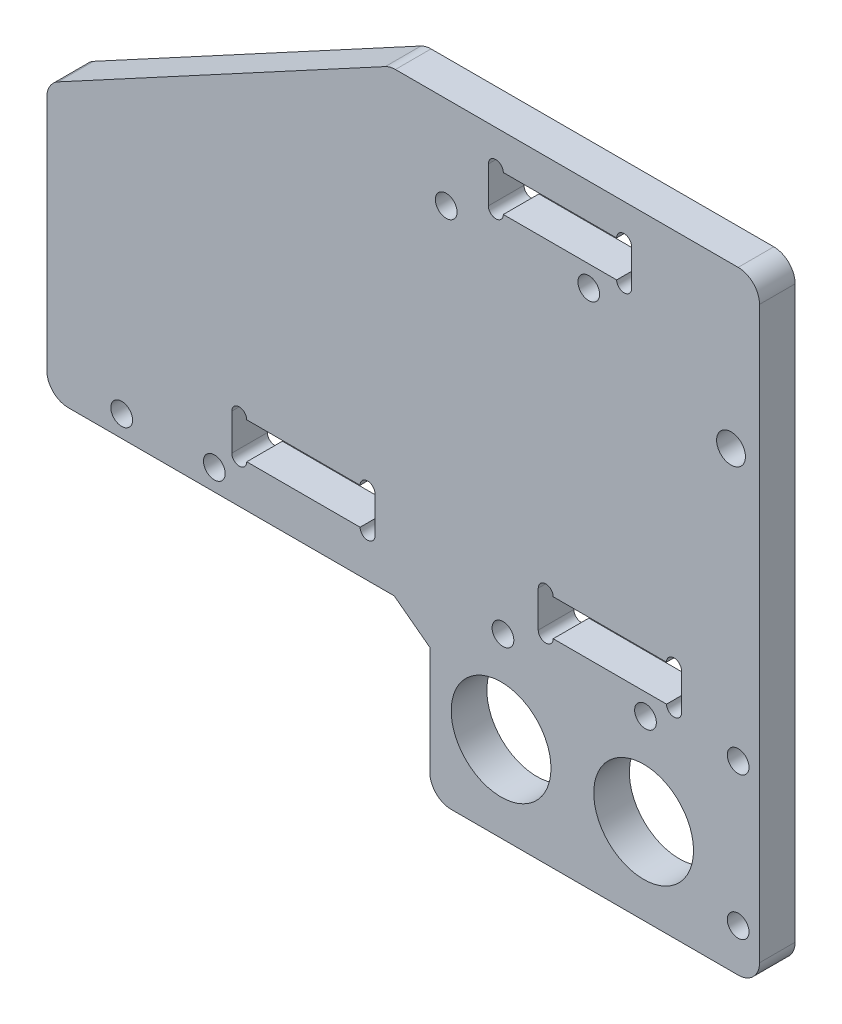
from build123d import *

# Parameters (mm, degrees)
EXTRUDE_1_DEPTH           = 5
SKETCH_4_W                = 20.1
SKETCH_4_H                = 5.1
CUT_EXTRUDE_3_DEPTH       = 1
CUT_EXTRUDE_3_DEPTH_BACK  = 6
CUT_EXTRUDE_4_DEPTH       = 6
SKETCH_6_R                = 1.525
CUT_EXTRUDE_5_DEPTH       = 1
CUT_EXTRUDE_5_DEPTH_BACK  = 6
CUT_EXTRUDE_6_DEPTH       = 1
CUT_EXTRUDE_6_DEPTH_BACK  = 6
SKETCH_8_W                = 53.737387097
SKETCH_8_H                = 38.025
EXTRUDE_2_DEPTH           = 5
SKETCH_11_R               = 1.525
CUT_EXTRUDE_9_DEPTH       = 1
CUT_EXTRUDE_9_DEPTH_BACK  = 6
SKETCH_14_R               = 2.025
CUT_EXTRUDE_10_DEPTH      = 10
SKETCH_15_W               = 2.1
SKETCH_15_H               = 5.1
SKETCH_15_W_2             = 15.9
CUT_EXTRUDE_11_DEPTH      = 6
SKETCH_16_R               = 1.525
CUT_EXTRUDE_12_DEPTH      = 1
CUT_EXTRUDE_12_DEPTH_BACK = 6
CUT_EXTRUDE_13_DEPTH      = 10
EXTRUDE_3_DEPTH           = 5
EXTRUDE_4_DEPTH           = 5
FILLET_1_R                = 3
SKETCH_20_R               = 7
CUT_EXTRUDE_14_DEPTH      = 5
SKETCH_21_R               = 1.525
CUT_EXTRUDE_15_DEPTH      = 8
CUT_EXTRUDE_17_DEPTH      = 6


with BuildPart() as part:
    # 草图1 → 凸台-拉伸1 (new body)
    with BuildSketch(Plane.XY):
        Polygon((0, 0), (-46.262612903, 16.838214056), (-46.262612903, 27.95), (-86.262612903, 27.95), (-100, 32.95), (-100, 87), (0, 87), align=None)
    extrude(amount=EXTRUDE_1_DEPTH)

    # 草图4 → 切除-拉伸3 (cut, two sides)
    with BuildSketch(Plane(origin=(0, 0, 0), x_dir=(-1, 0, 0), z_dir=(0, 0, -1))) as cut_extrude_3_sk:
        with Locations((28, 78.5)):
            Rectangle(SKETCH_4_W, SKETCH_4_H)
    extrude(amount=CUT_EXTRUDE_3_DEPTH, mode=Mode.SUBTRACT)
    extrude(cut_extrude_3_sk.sketch, amount=-CUT_EXTRUDE_3_DEPTH_BACK, mode=Mode.SUBTRACT)

    # 草图5 → 切除-拉伸4 (cut, through all)
    with BuildSketch(Plane(origin=(0, 0, 0), x_dir=(-1, 0, 0), z_dir=(0, 0, -1))):
        with BuildLine():
            Line((38.05, 81.05), (38.05, 75.95))
            ThreePointArc((38.05, 75.95), (37, 74.9), (35.95, 75.95))
            Line((35.95, 75.95), (35.95, 81.05))
            ThreePointArc((35.95, 81.05), (37, 82.1), (38.05, 81.05))
        make_face()
        with BuildLine():
            Line((17.95, 81.05), (17.95, 75.95))
            ThreePointArc((17.95, 75.95), (19, 74.9), (20.05, 75.95))
            Line((20.05, 75.95), (20.05, 81.05))
            ThreePointArc((20.05, 81.05), (19, 82.1), (17.95, 81.05))
        make_face()
    extrude(amount=-CUT_EXTRUDE_4_DEPTH, mode=Mode.SUBTRACT)

    # 草图6 → 切除-拉伸5 (cut, two sides)
    with BuildSketch(Plane(origin=(0, 0, 0), x_dir=(-1, 0, 0), z_dir=(0, 0, -1))) as cut_extrude_5_sk:
        with Locations((23.96256416, 73)):
            Circle(SKETCH_6_R)
        with Locations((43.96256416, 73)):
            Circle(SKETCH_6_R)
    extrude(amount=CUT_EXTRUDE_5_DEPTH, mode=Mode.SUBTRACT)
    extrude(cut_extrude_5_sk.sketch, amount=-CUT_EXTRUDE_5_DEPTH_BACK, mode=Mode.SUBTRACT)

    # 草图7 → 切除-拉伸6 (cut, two sides)
    with BuildSketch(Plane(origin=(0, 0, 0), x_dir=(-1, 0, 0), z_dir=(0, 0, -1))) as cut_extrude_6_sk:
        Polygon((50, 87), (100, 59.975), (100, 87), align=None)
    extrude(amount=CUT_EXTRUDE_6_DEPTH, mode=Mode.SUBTRACT)
    extrude(cut_extrude_6_sk.sketch, amount=-CUT_EXTRUDE_6_DEPTH_BACK, mode=Mode.SUBTRACT)

    # 草图8 → 凸台-拉伸2 (add)
    with BuildSketch(Plane(origin=(0, 0, 0), x_dir=(-1, 0, 0), z_dir=(0, 0, -1))):
        with Locations((73.131306451, 40.9625)):
            Rectangle(SKETCH_8_W, SKETCH_8_H)
    extrude(amount=-EXTRUDE_2_DEPTH)

    # 草图11 → 切除-拉伸9 (cut, two sides)
    with BuildSketch(Plane.XY.offset(5)) as cut_extrude_9_sk:
        with Locations((-3, 6)):
            Circle(SKETCH_11_R)
        with Locations((-3, 26)):
            Circle(SKETCH_11_R)
    extrude(amount=CUT_EXTRUDE_9_DEPTH, mode=Mode.SUBTRACT)
    extrude(cut_extrude_9_sk.sketch, amount=-CUT_EXTRUDE_9_DEPTH_BACK, mode=Mode.SUBTRACT)

    # 草图14 → 切除-拉伸10 (cut)
    with BuildSketch(Plane(origin=(0, 0, 0), x_dir=(-1, 0, 0), z_dir=(0, 0, -1))):
        with Locations((4, 63.499999999)):
            Circle(SKETCH_14_R)
    extrude(amount=-CUT_EXTRUDE_10_DEPTH, mode=Mode.SUBTRACT)

    # 草图15 → 切除-拉伸11 (cut, through all)
    with BuildSketch(Plane(origin=(0, 0, 0), x_dir=(-1, 0, 0), z_dir=(0, 0, -1))):
        with BuildLine():
            ThreePointArc((56.05, 33), (55, 34.05), (53.95, 33))
            Line((53.95, 33), (56.05, 33))
        make_face()
        with Locations((55, 30.45)):
            Rectangle(SKETCH_15_W, SKETCH_15_H)
        with Locations((64, 30.45)):
            Rectangle(SKETCH_15_W_2, SKETCH_15_H)
        with BuildLine():
            Line((56.05, 27.9), (53.95, 27.9))
            ThreePointArc((53.95, 27.9), (55, 26.85), (56.05, 27.9))
        make_face()
        with BuildLine():
            ThreePointArc((74.05, 33), (73, 34.05), (71.95, 33))
            Line((71.95, 33), (74.05, 33))
        make_face()
        with Locations((73, 30.45)):
            Rectangle(SKETCH_15_W, SKETCH_15_H)
        with BuildLine():
            Line((74.05, 27.9), (71.95, 27.9))
            ThreePointArc((71.95, 27.9), (73, 26.85), (74.05, 27.9))
        make_face()
        with Locations((12, 30.45)):
            Rectangle(SKETCH_15_W, SKETCH_15_H)
        with BuildLine():
            Line((13.05, 27.9), (10.95, 27.9))
            ThreePointArc((10.95, 27.9), (12, 26.85), (13.05, 27.9))
        make_face()
        with Locations((21, 30.45)):
            Rectangle(SKETCH_15_W_2, SKETCH_15_H)
        with BuildLine():
            ThreePointArc((13.05, 33), (12, 34.05), (10.95, 33))
            Line((10.95, 33), (13.05, 33))
        make_face()
        with Locations((30, 30.45)):
            Rectangle(SKETCH_15_W, SKETCH_15_H)
        with BuildLine():
            Line((31.05, 27.9), (28.95, 27.9))
            ThreePointArc((28.95, 27.9), (30, 26.85), (31.05, 27.9))
        make_face()
        with BuildLine():
            ThreePointArc((31.05, 33), (30, 34.05), (28.95, 33))
            Line((28.95, 33), (31.05, 33))
        make_face()
    extrude(amount=-CUT_EXTRUDE_11_DEPTH, mode=Mode.SUBTRACT)

    # 草图16 → 切除-拉伸12 (cut, two sides)
    with BuildSketch(Plane(origin=(0, 0, 0), x_dir=(-1, 0, 0), z_dir=(0, 0, -1))) as cut_extrude_12_sk:
        with Locations((16, 24.95)):
            Circle(SKETCH_16_R)
        with Locations((36, 24.95)):
            Circle(SKETCH_16_R)
    extrude(amount=CUT_EXTRUDE_12_DEPTH, mode=Mode.SUBTRACT)
    extrude(cut_extrude_12_sk.sketch, amount=-CUT_EXTRUDE_12_DEPTH_BACK, mode=Mode.SUBTRACT)

    # 草图17 → 切除-拉伸13 (cut)
    with BuildSketch(Plane(origin=(0, 0, 0), x_dir=(-1, 0, 0), z_dir=(0, 0, -1))):
        Polygon((0, 86), (51.85013876, 86), (50, 87), (0, 87), align=None)
    extrude(amount=-CUT_EXTRUDE_13_DEPTH, mode=Mode.SUBTRACT)

    # 草图18 → 凸台-拉伸3 (add)
    with BuildSketch(Plane.XY.offset(5)):
        Polygon((-46.262612903, 16.838214056), (-46.262612903, 0), (0, 0), align=None)
    extrude(amount=-EXTRUDE_3_DEPTH)

    # 草图19 → 凸台-拉伸4 (add)
    with BuildSketch(Plane.XY.offset(5)):
        Polygon((-46.262612903, 6.95), (-66.262612903, 21.95), (-46.262612903, 21.95), align=None)
    extrude(amount=-EXTRUDE_4_DEPTH)

    # 圆角1
    fillet_1_edges = [part.edges().sort_by_distance(p)[0] for p in [
        (-100, 21.95, 2.5),
        (0, 0, 2.5),
        (-51.85013876, 86, 2.5),
        (0, 86, 2.5),
        (-46.262612903, 0, 2.5),
        (-100, 59.975, 2.5),
    ]]
    fillet(fillet_1_edges, radius=FILLET_1_R)

    # 草图20 → 切除-拉伸14 (cut)
    with BuildSketch(Plane.XY.offset(5)):
        with Locations((-36.262612903, 12)):
            Circle(SKETCH_20_R)
        with Locations((-16.262612903, 12)):
            Circle(SKETCH_20_R)
    extrude(amount=-CUT_EXTRUDE_14_DEPTH, mode=Mode.SUBTRACT)

    # 草图21 → 切除-拉伸15 (cut)
    with BuildSketch(Plane.XY.offset(5)):
        with Locations((-89.5, 24.95)):
            Circle(SKETCH_21_R)
        with Locations((-76.5, 24.95)):
            Circle(SKETCH_21_R)
    extrude(amount=-CUT_EXTRUDE_15_DEPTH, mode=Mode.SUBTRACT)

    # 草图23 → 切除-拉伸17 (cut, through all)
    with BuildSketch(Plane(origin=(0, 0, 0), x_dir=(-1, 0, 0), z_dir=(0, 0, -1))):
        Polygon((46.262612903, 18.2), (46.262612903, 6.95), (66.262612903, 21.95), (51.262612903, 21.95), align=None)
    extrude(amount=-CUT_EXTRUDE_17_DEPTH, mode=Mode.SUBTRACT)


solid = part.part
